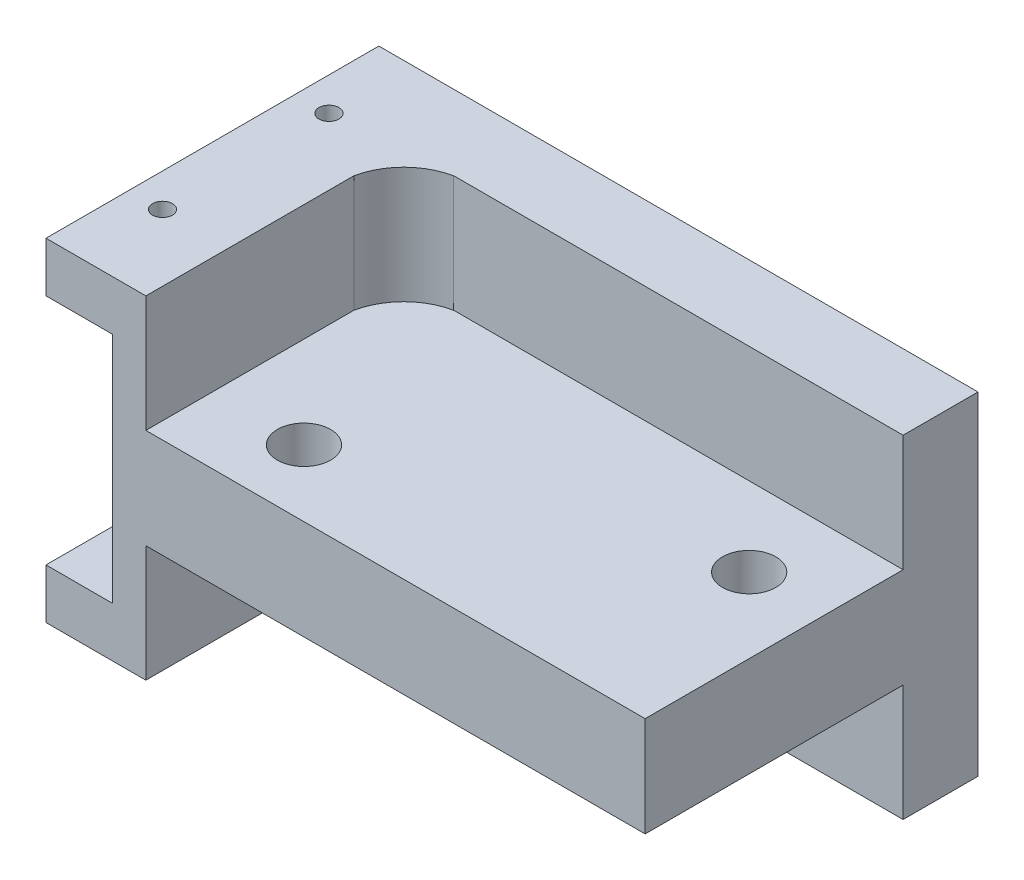
from build123d import *

# Parameters (mm, degrees)
SKETCH1_W           = 35
SKETCH1_H           = 20
BOSS_EXTRUDE2_DEPTH = 10
CUT_EXTRUDE1_DEPTH  = 7
CUT_EXTRUDE2_DEPTH  = 7
SKETCH8_R           = 1.6
CUT_EXTRUDE3_DEPTH  = 7
SKETCH9_W           = 20
SKETCH9_H           = 14
CUT_EXTRUDE4_DEPTH  = 3
SKETCH10_R          = 0.6
CUT_EXTRUDE5_DEPTH  = 3
SKETCH11_R          = 0.6
CUT_EXTRUDE6_DEPTH  = 3
SKETCH12_W          = 20
SKETCH12_H          = 3
BOSS_EXTRUDE3_DEPTH = 1
SKETCH13_W          = 20
SKETCH13_H          = 3
BOSS_EXTRUDE4_DEPTH = 1


with BuildPart() as part:
    # Sketch1 → Boss-Extrude2 (new body, symmetric)
    with BuildSketch(Plane(origin=(0, 0, 0), x_dir=(1, 0, 0), z_dir=(0, 1, 0))):
        Rectangle(SKETCH1_W, SKETCH1_H)
    extrude(amount=BOSS_EXTRUDE2_DEPTH, both=True)

    # Sketch4 → Cut-Extrude1 (cut)
    with BuildSketch(Plane(origin=(0, 10, 0), x_dir=(1, 0, 0), z_dir=(0, 1, 0))):
        with BuildLine():
            Line((-12.5, -10), (-12.5, 2.5))
            ThreePointArc((-12.5, 2.5), (-11.447225408, 4.447225408), (-9.5, 5.5))
            Line((-9.5, 5.5), (17.5, 5.5))
            Line((17.5, 5.5), (17.5, -10))
            Line((17.5, -10), (-12.5, -10))
        make_face()
    extrude(amount=-CUT_EXTRUDE1_DEPTH, mode=Mode.SUBTRACT)

    # Sketch6 → Cut-Extrude2 (cut)
    with BuildSketch(Plane.XZ.offset(10)):
        with BuildLine():
            Line((-12.5, 10), (-12.5, -2.5))
            ThreePointArc((-12.5, -2.5), (-11.528297563, -4.528297563), (-9.5, -5.5))
            Line((-9.5, -5.5), (17.5, -5.5))
            Line((17.5, -5.5), (17.5, 10))
            Line((17.5, 10), (-12.5, 10))
        make_face()
    extrude(amount=-CUT_EXTRUDE2_DEPTH, mode=Mode.SUBTRACT)

    # Sketch8 → Cut-Extrude3 (cut)
    with BuildSketch(Plane(origin=(0, 3, 0), x_dir=(1, 0, 0), z_dir=(0, 1, 0))):
        with Locations((-7, -6)):
            Circle(SKETCH8_R)
        with Locations((13, 0.75)):
            Circle(SKETCH8_R)
    extrude(amount=-CUT_EXTRUDE3_DEPTH, mode=Mode.SUBTRACT)

    # Sketch9 → Cut-Extrude4 (cut)
    with BuildSketch(Plane.ZY.offset(17.5)):
        Rectangle(SKETCH9_W, SKETCH9_H)
    extrude(amount=-CUT_EXTRUDE4_DEPTH, mode=Mode.SUBTRACT)

    # Sketch10 → Cut-Extrude5 (cut)
    with BuildSketch(Plane(origin=(0, 10, 0), x_dir=(1, 0, 0), z_dir=(0, 1, 0))):
        with Locations((-16.5, 5)):
            Circle(SKETCH10_R)
        with Locations((-16.5, -5)):
            Circle(SKETCH10_R)
    extrude(amount=-CUT_EXTRUDE5_DEPTH, mode=Mode.SUBTRACT)

    # Sketch11 → Cut-Extrude6 (cut)
    with BuildSketch(Plane.XZ.offset(10)):
        with Locations((-16.5, 5)):
            Circle(SKETCH11_R)
        with Locations((-16.5, -5)):
            Circle(SKETCH11_R)
    extrude(amount=-CUT_EXTRUDE6_DEPTH, mode=Mode.SUBTRACT)

    # Sketch12 → Boss-Extrude3 (add)
    with BuildSketch(Plane.ZY.offset(17.5)):
        with Locations((0, 8.5)):
            Rectangle(SKETCH12_W, SKETCH12_H)
    extrude(amount=BOSS_EXTRUDE3_DEPTH)

    # Sketch13 → Boss-Extrude4 (add)
    with BuildSketch(Plane.ZY.offset(17.5)):
        with Locations((0, -8.5)):
            Rectangle(SKETCH13_W, SKETCH13_H)
    extrude(amount=BOSS_EXTRUDE4_DEPTH)


solid = part.part
